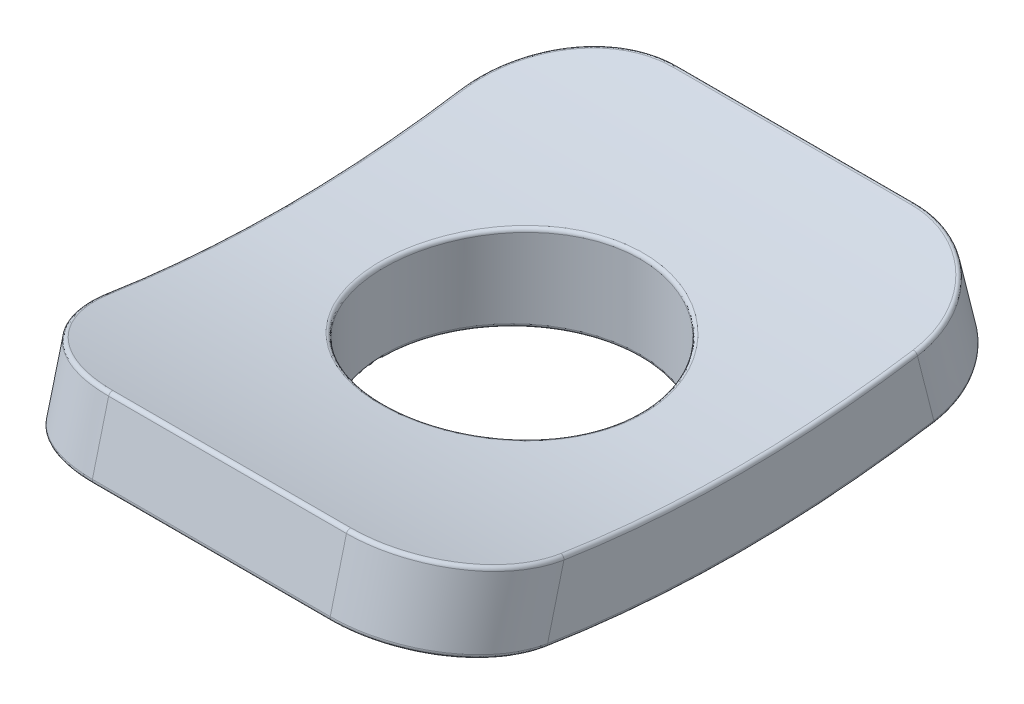
from build123d import *

# Parameters (mm, degrees)
BOSS_EXTRUDE1_DEPTH     = 6.25
FILLET1_R               = 3
CUT_EXTRUDE1_DEPTH      = 11.535374407
CUT_EXTRUDE1_DEPTH_BACK = 11.535374407
SKETCH2_R               = 3.5
BOSS_EXTRUDE2_REACH     = 14.785
BOSS_EXTRUDE2_START     = -2.25
SKETCH2_3_R             = 6
SKETCH2_3_R_2           = 3.5
FILLET2_R               = 0.1


with BuildPart() as part:
    # Sketch1 → Boss-Extrude1 (new, symmetric)
    with BuildSketch(Plane(origin=(0, 0, 0), x_dir=(0, 0, -1), z_dir=(1, 0, 0))):
        with BuildLine():
            Line((-7.75, 0.968254226), (-8.242063492, -0.970269315))
            ThreePointArc((-8.242063492, -0.970269315), (0, -2), (8.242063492, -0.970269315))
            Line((8.242063492, -0.970269315), (7.75, 0.968254226))
            ThreePointArc((7.75, 0.968254226), (0, 0), (-7.75, 0.968254226))
        make_face()
    extrude(amount=BOSS_EXTRUDE1_DEPTH, both=True)

    # Fillet1
    fillet1_edges = [part.edges().sort_by_distance(p)[0] for p in [
        (-6.25, -0.001007544, 7.996031746),
        (-6.25, -0.001007544, -7.996031746),
        (6.25, -0.001007544, -7.996031746),
        (6.25, -0.001007544, 7.996031746),
    ]]
    fillet(fillet1_edges, radius=FILLET1_R)

    # Sketch2 → Cut-Extrude1 (cut, two sides: drawn at the far end of the back side and taken through both)
    with BuildSketch(Plane(origin=(0, 0, 0), x_dir=(1, 0, 0), z_dir=(0, 1, 0)).offset(-CUT_EXTRUDE1_DEPTH_BACK)):
        Circle(SKETCH2_R)
    extrude(amount=CUT_EXTRUDE1_DEPTH + CUT_EXTRUDE1_DEPTH_BACK, mode=Mode.SUBTRACT)

    # Sketch2_3 → Boss-Extrude2 (add, up to next)
    with BuildSketch(Plane(origin=(0, 0, 0), x_dir=(1, 0, 0), z_dir=(0, 1, 0)).offset(BOSS_EXTRUDE2_START), mode=Mode.PRIVATE) as boss_extrude2_sk1:
        Circle(SKETCH2_3_R)
        Circle(SKETCH2_3_R_2, mode=Mode.SUBTRACT)
    boss_extrude2_tool1 = extrude(boss_extrude2_sk1.sketch, amount=BOSS_EXTRUDE2_REACH, mode=Mode.PRIVATE) - part.part
    add(boss_extrude2_tool1.solids().sort_by_distance((-5.830294, -2.25, 0))[0])

    # Fillet2
    fillet2_edges = [part.edges().sort_by_distance(p)[0] for p in [
        (-3.5, -2.25, 0),
        (0, 0.195048311, -3.499999998),
        (-6.25, 0, 0),
        (-6.25, -2, 0),
        (6.25, 0, 0),
        (6.25, -2, 0),
        (0, 0.968254226, -7.75),
        (0, -0.970269315, 8.242063492),
        (0, 0.968254226, 7.75),
        (5.372620906, -1.175568198, 7.386287474),
        (5.372620851, -1.175568189, -7.386287533),
        (-5.372620851, -1.175568189, -7.386287533),
        (-5.372620906, -1.175568198, 7.386287474),
        (5.372791929, 0.763629512, 6.893876245),
        (5.37279201, 0.763629491, -6.893876098),
        (-5.37279201, 0.763629491, -6.893876098),
        (-5.372791929, 0.763629512, 6.893876245),
        (-6, -2.25, 0),
        (0, -0.970269315, -8.242063492),
    ]]
    fillet(fillet2_edges, radius=FILLET2_R)


solid = part.part
